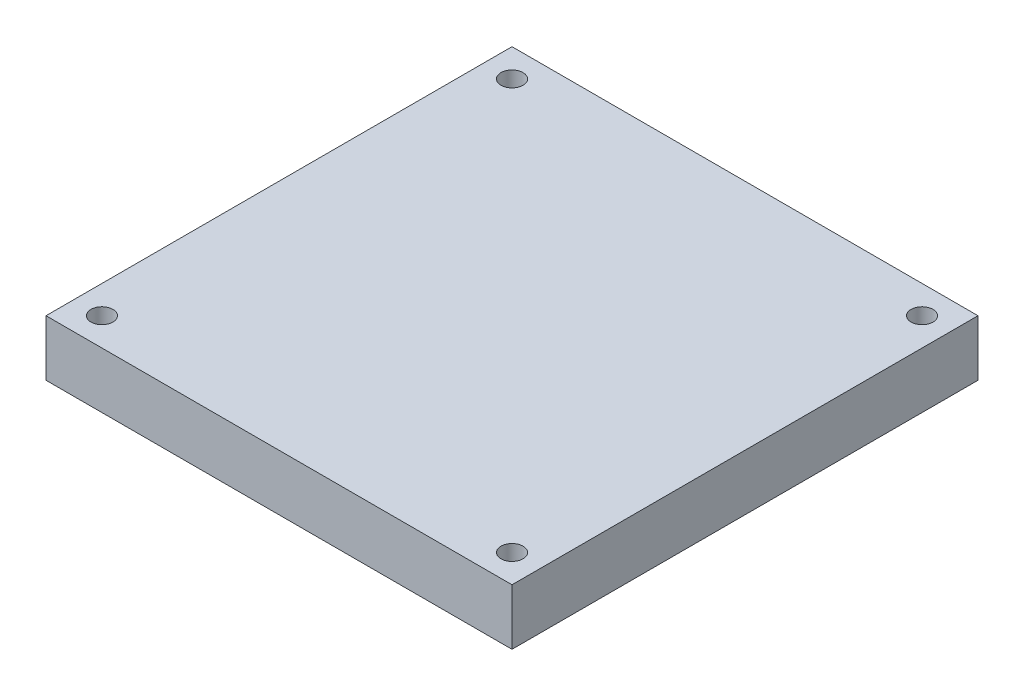
from build123d import *

# Parameters (mm, degrees)
SKETCH1_W                       = 63.5
SKETCH1_H                       = 63.5
BOSS_EXTRUDE1_DEPTH             = 7.62
F_3_0MM_DOWEL_HOLE1_D           = 3
F_3_0MM_DOWEL_HOLE1_DEPTH       = 7.62
F_3_0MM_DOWEL_HOLE1_CSINK_D     = 3.05
F_3_0MM_DOWEL_HOLE1_CSINK_ANGLE = 90
LPATTERN1_COUNT                 = 2
LPATTERN1_PITCH                 = 55.88
LPATTERN1_COUNT_DIR2            = 2
LPATTERN1_PITCH_DIR2            = 55.88
SKETCH6_R                       = 12.7
CUT_EXTRUDE1_DEPTH              = 6.35


with BuildPart() as part:
    # Sketch1 → Boss-Extrude1 (new body)
    with BuildSketch(Plane(origin=(0, 0, 0), x_dir=(1, 0, 0), z_dir=(0, 1, 0))):
        Rectangle(SKETCH1_W, SKETCH1_H)
    extrude(amount=BOSS_EXTRUDE1_DEPTH)

    # Ø3.0mm Dowel Hole1
    with Locations(Plane(origin=(0, 0, 0), x_dir=(-1, 0, 0), z_dir=(0, -1, 0))):
        with Locations((-27.94, -27.94)):
            f_3_0mm_dowel_hole1 = CounterSinkHole(F_3_0MM_DOWEL_HOLE1_D / 2, F_3_0MM_DOWEL_HOLE1_CSINK_D / 2, depth=F_3_0MM_DOWEL_HOLE1_DEPTH, counter_sink_angle=F_3_0MM_DOWEL_HOLE1_CSINK_ANGLE)

    # LPattern1: 3.0mm Dowel Hole1 2 × 2
    with Locations(*[(-j * LPATTERN1_PITCH_DIR2, 0, -i * LPATTERN1_PITCH) for i in range(LPATTERN1_COUNT) for j in range(LPATTERN1_COUNT_DIR2) if (i, j) != (0, 0)]):
        add(f_3_0mm_dowel_hole1, mode=Mode.SUBTRACT)

    # Sketch6 → Cut-Extrude1 (cut)
    with BuildSketch(Plane.XZ):
        Circle(SKETCH6_R)
    extrude(amount=-CUT_EXTRUDE1_DEPTH, mode=Mode.SUBTRACT)


solid = part.part
